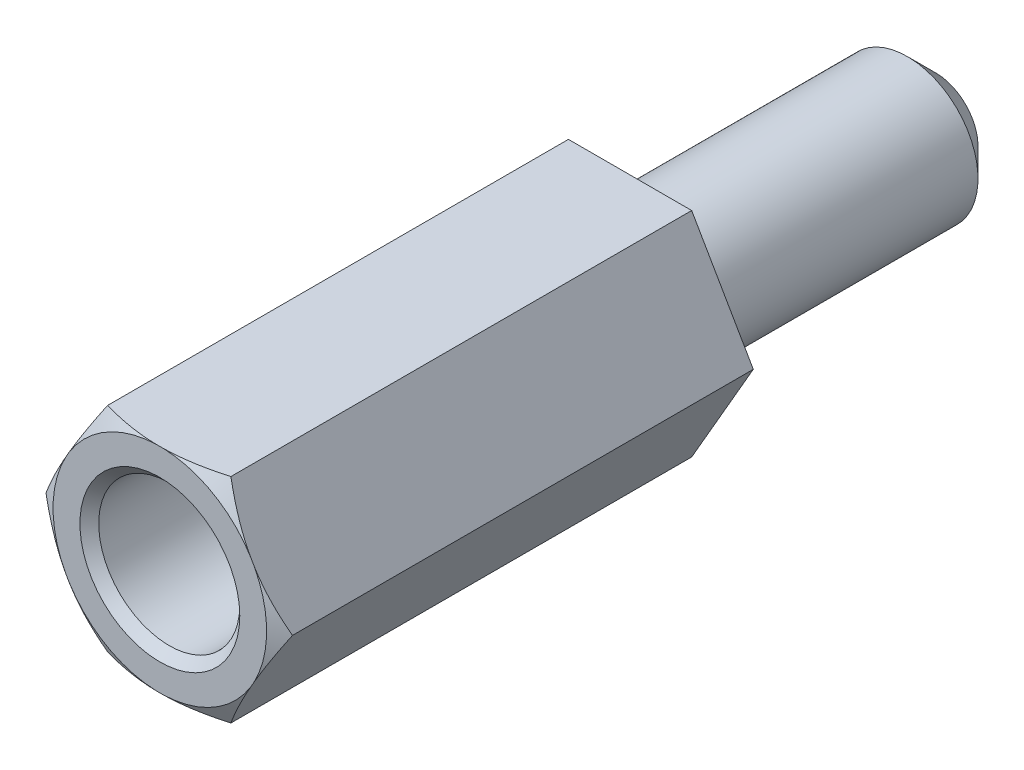
from build123d import *

# Parameters (mm, degrees)
BOSS_EXTRUDE1_DEPTH     = 10
SKETCH2_R               = 1.5
CUT_EXTRUDE1_DEPTH      = 1
CUT_EXTRUDE1_DEPTH_BACK = 9
CHAMFER1_SIZE           = 0.2
SKETCH4_R               = 1.5
BOSS_EXTRUDE2_DEPTH     = 6.5
CHAMFER2_SIZE           = 0.6


with BuildPart() as part:
    # Sketch1 → Boss-Extrude1 (new body)
    with BuildSketch(Plane.XY):
        Polygon((2.621170222, 0), (1.310585111, 2.27), (-1.310585111, 2.27), (-2.621170222, 0), (-1.310585111, -2.27), (1.310585111, -2.27), align=None)
    extrude(amount=BOSS_EXTRUDE1_DEPTH)

    # Sketch2 → Cut-Extrude1 (cut, two sides)
    with BuildSketch(Plane.XY.offset(10)) as cut_extrude1_sk:
        Circle(SKETCH2_R)
    extrude(amount=CUT_EXTRUDE1_DEPTH, mode=Mode.SUBTRACT)
    extrude(cut_extrude1_sk.sketch, amount=-CUT_EXTRUDE1_DEPTH_BACK, mode=Mode.SUBTRACT)

    # Sketch3 → Cut-Revolve1 (revolve, cut)
    with BuildSketch(Plane(origin=(0, 0, 0), x_dir=(1, 0, 0), z_dir=(0, 1, 0))):
        Polygon((-2.621170222, -10), (-2.271170222, -10), (-2.621170222, -9.8), align=None)
    revolve(axis=Axis((0, 0, 1), (0, 0, 1)), mode=Mode.SUBTRACT)

    # Chamfer1
    chamfer1_edges = [part.edges().sort_by_distance(p)[0] for p in [
        (-1.5, 0, 10),
    ]]
    chamfer(chamfer1_edges, length=CHAMFER1_SIZE)

    # Sketch4 → Boss-Extrude2 (add)
    with BuildSketch(Plane(origin=(0, 0, 0), x_dir=(-1, 0, 0), z_dir=(0, 0, -1))):
        Circle(SKETCH4_R)
    extrude(amount=BOSS_EXTRUDE2_DEPTH)

    # Chamfer2
    chamfer2_edges = [part.edges().sort_by_distance(p)[0] for p in [
        (1.5, 0, -6.5),
    ]]
    chamfer(chamfer2_edges, length=CHAMFER2_SIZE)


solid = part.part
